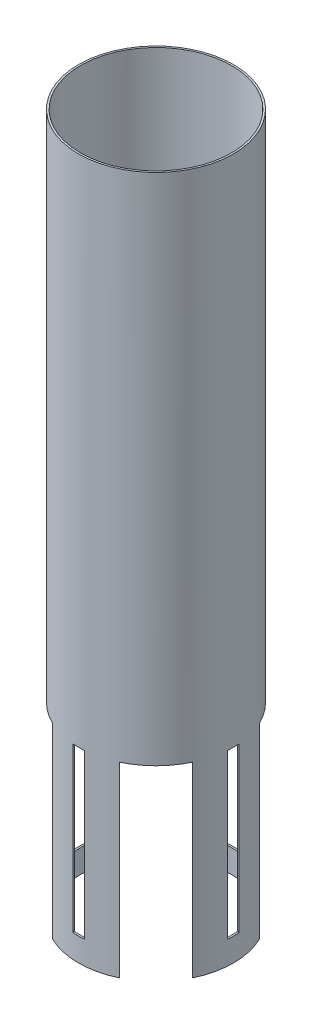
from build123d import *

# Parameters (mm, degrees)
SKETCH1_R           = 33.16
SKETCH1_R_2         = 32.385
BOSS_EXTRUDE1_DEPTH = 150
SKETCH2_W           = 5
SKETCH2_H           = 70
CUT_EXTRUDE1_DEPTH  = 34.16
CIRPATTERN1_COUNT   = 4
SKETCH3_W           = 22
SKETCH3_H           = 80
CUT_EXTRUDE2_DEPTH  = 26.831770005
CIRPATTERN2_COUNT   = 4


with BuildPart() as part:
    # Sketch1 → Boss-Extrude1 (new body, symmetric)
    with BuildSketch(Plane(origin=(0, 0, 0), x_dir=(1, 0, 0), z_dir=(0, 1, 0))):
        Circle(SKETCH1_R)
        Circle(SKETCH1_R_2, mode=Mode.SUBTRACT)
    extrude(amount=BOSS_EXTRUDE1_DEPTH, both=True)

    # Sketch2 → Cut-Extrude1 (cut, through all)
    with BuildSketch(Plane.XY):
        with Locations((0, -105)):
            Rectangle(SKETCH2_W, SKETCH2_H)
    cut_extrude1 = extrude(amount=-CUT_EXTRUDE1_DEPTH, mode=Mode.SUBTRACT)

    # CirPattern1: Cut-Extrude1 ×4 about axis
    cirpattern1_axis = Axis((0, 0, 0), (0, 1, 0))
    for i in range(1, CIRPATTERN1_COUNT):
        add(cut_extrude1.rotate(cirpattern1_axis, i * 360 / CIRPATTERN1_COUNT), mode=Mode.SUBTRACT)

    # Sketch3 → Cut-Extrude2 (cut, through all)
    with BuildSketch(Plane(origin=(14.894180259, 0, 14.894180259), x_dir=(-0.707106781, 0, 0.707106781), z_dir=(-0.707106781, 0, -0.707106781))):
        with Locations((0, -110)):
            Rectangle(SKETCH3_W, SKETCH3_H)
    cut_extrude2 = extrude(amount=-CUT_EXTRUDE2_DEPTH, mode=Mode.SUBTRACT)

    # CirPattern2: Cut-Extrude2 ×4 about axis
    cirpattern2_axis = Axis((0, 0, 0), (0, 1, 0))
    for i in range(1, CIRPATTERN2_COUNT):
        add(cut_extrude2.rotate(cirpattern2_axis, i * 360 / CIRPATTERN2_COUNT), mode=Mode.SUBTRACT)


solid = part.part
